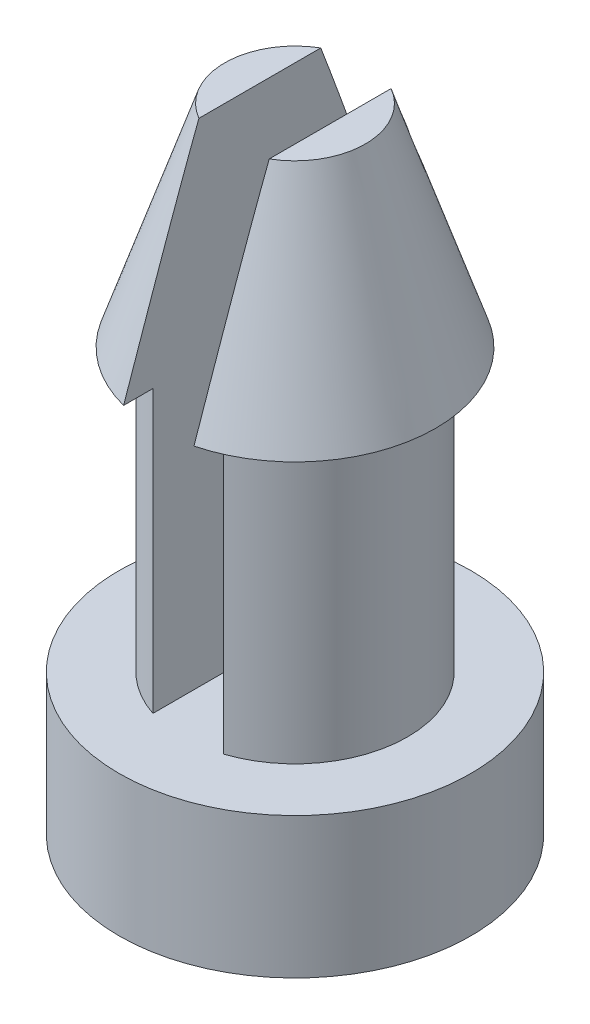
from build123d import *

# Parameters (mm, degrees)
SKETCH1_W               = 2.54
SKETCH1_H               = 6.35
SKETCH2_W               = 1.5875
SKETCH2_H               = 11.1125
CUT_EXTRUDE1_DEPTH      = 4.96875
CUT_EXTRUDE1_DEPTH_BACK = 4.96875


with BuildPart() as part:
    # Sketch1 → Revolve1 (revolve)
    with BuildSketch(Plane(origin=(0, 0, 0), x_dir=(0, 0, -1), z_dir=(1, 0, 0))):
        Polygon((0, 3.175), (0, 0), (3.96875, 0), (3.96875, 3.175), (2.54, 3.175), align=None)
        with Locations((1.27, 6.35)):
            Rectangle(SKETCH1_W, SKETCH1_H)
        Polygon((0, 14.2875), (0, 9.525), (2.54, 9.525), (3.175, 9.525), (1.5875, 14.2875), align=None)
    revolve(axis=Axis((0, 0, 0), (0, 1, 0)))

    # Sketch2 → Cut-Extrude1 (cut, two sides)
    with BuildSketch(Plane.XY) as cut_extrude1_sk:
        with Locations((0, 8.73125)):
            Rectangle(SKETCH2_W, SKETCH2_H)
    extrude(amount=CUT_EXTRUDE1_DEPTH, mode=Mode.SUBTRACT)
    extrude(cut_extrude1_sk.sketch, amount=-CUT_EXTRUDE1_DEPTH_BACK, mode=Mode.SUBTRACT)


solid = part.part
